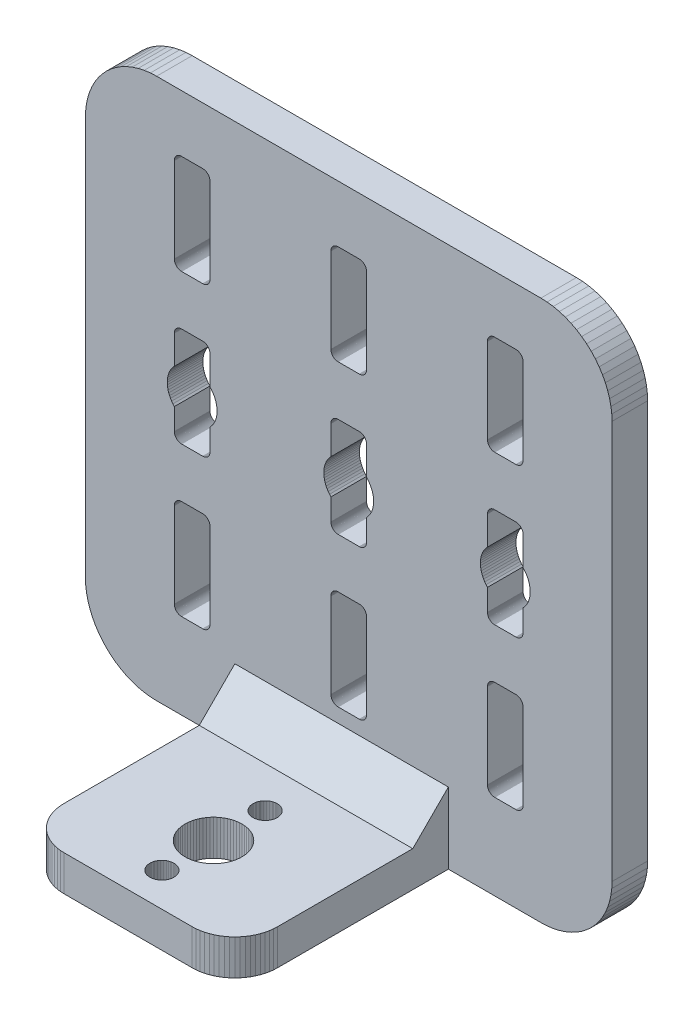
from build123d import *

# Parameters (mm, degrees)
BOSS_EXTRUDE1_DEPTH = 4.999999888
CUT_EXTRUDE1_DEPTH  = 5.999999888
CUT_EXTRUDE2_DEPTH  = 5.999999888
CUT_EXTRUDE3_DEPTH  = 5.999999888
CUT_EXTRUDE4_DEPTH  = 5.999999888
CUT_EXTRUDE5_DEPTH  = 5.999999888
CUT_EXTRUDE6_DEPTH  = 5.999999888
CUT_EXTRUDE7_DEPTH  = 5.999999888
CUT_EXTRUDE8_DEPTH  = 5.999999888
BOSS_EXTRUDE2_DEPTH = 4.999999888
CUT_EXTRUDE9_DEPTH  = 5.999999888
CUT_EXTRUDE10_DEPTH = 5.999999888
CUT_EXTRUDE11_DEPTH = 5.999999888
CUT_EXTRUDE12_DEPTH = 5.999999888
CHAMFER1_SIZE       = 4.999999888


with BuildPart() as part:
    # Sketch1 → Boss-Extrude1 (new body)
    with BuildSketch(Plane(origin=(0, 0, 0), x_dir=(-1, 0, 0), z_dir=(0, 0, -1))):
        Polygon((-0.037951017, 9.128620305), (9.5022e-05, 10.000177294), (9.5022e-05, 66.00017716), (-0.038050115, 66.87156111), (-0.151921064, 67.73648411), (-0.340741128, 68.588189781), (-0.603072345, 69.420203567), (-0.936921744, 70.226185024), (-1.339744776, 71.000002325), (-1.808479428, 71.73576206), (-2.339553088, 72.427876294), (-2.928931266, 73.071070015), (-3.57212103, 73.660440743), (-4.264235497, 74.191518128), (-4.999998957, 74.660256505), (-5.773816258, 75.063079596), (-6.579797715, 75.396925211), (-7.411808241, 75.659260154), (-8.263517171, 75.848080218), (-9.128440171, 75.961947441), (-9.999997914, 75.999997556), (-63.999995589, 75.999997556), (-64.871557057, 75.961947441), (-65.736480057, 75.848080218), (-66.588193178, 75.659260154), (-67.420199513, 75.396925211), (-68.226180971, 75.063079596), (-68.999998271, 74.660256505), (-69.735765457, 74.191518128), (-70.427879691, 73.660440743), (-71.071065962, 73.071070015), (-71.66044414, 72.427876294), (-72.191521525, 71.73576206), (-72.660252452, 71.000002325), (-73.063075542, 70.226185024), (-73.396921158, 69.420203567), (-73.659256101, 68.588189781), (-73.848076165, 67.73648411), (-73.961943388, 66.87156111), (-74.000000954, 65.999999642), (-74.000000954, 9.999999776), (-73.961943388, 9.128442965), (-73.848076165, 8.263518102), (-73.659256101, 7.411809638), (-73.396921158, 6.579798646), (-73.156759143, 6.000000052), (-73.063071255, 5.773818965), (-72.660233496, 5.0000093), (-72.191488623, 4.264253794), (-71.660398119, 3.572152188), (-71.071007749, 2.928971734), (-70.427810306, 2.339607377), (-69.735686005, 1.808544393), (-68.999909934, 1.339824735), (-68.226084998, 0.937015615), (-67.420097212, 0.603182541), (-66.588085905, 0.34086628), (-65.736369205, 0.152063132), (-64.871444046, 0.03821007), (-63.999881857, 0.000173573), (-9.999884182, 0.000173573), (-9.128326439, 0.038226591), (-8.263403439, 0.152096048), (-7.411694509, 0.340915341), (-6.579683983, 0.603247374), (-5.773702526, 0.937095725), (-4.999885225, 1.339919514), (-4.264121764, 1.808653118), (-3.572007298, 2.339729222), (-2.928817534, 2.929105771), (-2.339439356, 3.572297397), (-1.808365696, 4.26440907), (-1.339631044, 5.000173461), (-0.936808012, 5.773990762), (-0.843120628, 6.000173625), (-0.602961325, 6.579973343), (-0.340634, 7.411985562), (-0.151817919, 8.263694909), align=None)
    extrude(amount=-BOSS_EXTRUDE1_DEPTH)

    # Sketch2 → Cut-Extrude1 (cut, through all)
    with BuildSketch(Plane(origin=(0, 0, 0), x_dir=(-1, 0, 0), z_dir=(0, 0, -1))):
        Polygon((-12.999998406, 12.133974582), (-12.92642206, 12.180848047), (-12.857211754, 12.233955786), (-12.792890891, 12.292893603), (-12.733954936, 12.357212603), (-12.680847198, 12.42642384), (-12.633973733, 12.500000186), (-12.593690306, 12.577381916), (-12.560306117, 12.657979503), (-12.534072623, 12.741181068), (-12.515190989, 12.826351449), (-12.503804639, 12.912844308), (-12.499999255, 13.000000268), (-12.499999255, 25.000000373), (-12.503804639, 25.087155402), (-12.515190989, 25.173647329), (-12.534072623, 25.258820504), (-12.560306117, 25.342019275), (-12.593690306, 25.422617793), (-12.633973733, 25.499999523), (-12.680847198, 25.573575869), (-12.733954936, 25.642788038), (-12.792890891, 25.707107037), (-12.857211754, 25.766044855), (-12.92642206, 25.819152594), (-12.999998406, 25.866026059), (-13.077380136, 25.906307623), (-13.157978654, 25.939691812), (-13.241179287, 25.965925306), (-13.3263506, 25.98480694), (-13.412842527, 25.996195152), (-13.499997556, 26.000000536), (-16.499998048, 26.000000536), (-16.58715494, 25.996195152), (-16.673646867, 25.98480694), (-16.758818179, 25.965925306), (-16.842018813, 25.939691812), (-16.922617331, 25.906307623), (-17.000000924, 25.866026059), (-17.073575407, 25.819152594), (-17.142785713, 25.766044855), (-17.207104713, 25.707107037), (-17.266042531, 25.642788038), (-17.319150269, 25.573575869), (-17.366023734, 25.499999523), (-17.406307161, 25.422617793), (-17.43969135, 25.342019275), (-17.465924844, 25.258820504), (-17.484806478, 25.173647329), (-17.496192828, 25.087155402), (-17.499998212, 25.000000373), (-17.499998212, 13.000000268), (-17.496192828, 12.912844308), (-17.484806478, 12.826351449), (-17.465924844, 12.741181068), (-17.43969135, 12.657979503), (-17.406307161, 12.577381916), (-17.366023734, 12.500000186), (-17.319150269, 12.42642384), (-17.266042531, 12.357212603), (-17.207104713, 12.292893603), (-17.142785713, 12.233955786), (-17.073575407, 12.180848047), (-17.000000924, 12.133974582), (-16.922617331, 12.093692087), (-16.842018813, 12.060306966), (-16.758818179, 12.034074403), (-16.673646867, 12.015191838), (-16.58715494, 12.003805488), (-16.499998048, 12.000000104), (-13.499997556, 12.000000104), (-13.412842527, 12.003805488), (-13.3263506, 12.015191838), (-13.241179287, 12.034074403), (-13.157978654, 12.060306966), (-13.077380136, 12.093692087), align=None)
    extrude(amount=-CUT_EXTRUDE1_DEPTH, mode=Mode.SUBTRACT)

    # Sketch3 → Cut-Extrude2 (cut, through all)
    with BuildSketch(Plane(origin=(0, 0, 0), x_dir=(-1, 0, 0), z_dir=(0, 0, -1))):
        Polygon((-39.207104594, 25.707107037), (-39.266042411, 25.642788038), (-39.31915015, 25.573575869), (-39.366025478, 25.499999523), (-39.406307042, 25.422617793), (-39.439689368, 25.342019275), (-39.465922862, 25.258820504), (-39.484806359, 25.173647329), (-39.496194571, 25.087155402), (-39.500001818, 25.000000373), (-39.500001818, 13.000000268), (-39.496194571, 12.912844308), (-39.484806359, 12.826351449), (-39.465922862, 12.741181068), (-39.439689368, 12.657979503), (-39.406307042, 12.577381916), (-39.366025478, 12.500000186), (-39.31915015, 12.42642384), (-39.266042411, 12.357212603), (-39.207104594, 12.292893603), (-39.142787457, 12.233955786), (-39.073575288, 12.180848047), (-38.999997079, 12.133974582), (-38.922615349, 12.093692087), (-38.842018694, 12.060306966), (-38.75881806, 12.034074403), (-38.673646748, 12.015191838), (-38.587152958, 12.003805488), (-38.499999791, 12.000000104), (-35.499997437, 12.000000104), (-35.41284427, 12.003805488), (-35.32635048, 12.015191838), (-35.241179168, 12.034074403), (-35.157978535, 12.060306966), (-35.077381879, 12.093692087), (-35.000000149, 12.133974582), (-34.92642194, 12.180848047), (-34.857209772, 12.233955786), (-34.792892635, 12.292893603), (-34.733954817, 12.357212603), (-34.680847079, 12.42642384), (-34.633971751, 12.500000186), (-34.593690187, 12.577381916), (-34.560304135, 12.657979503), (-34.534074366, 12.741181068), (-34.51519087, 12.826351449), (-34.503802657, 12.912844308), (-34.499999136, 13.000000268), (-34.499999136, 25.000000373), (-34.503802657, 25.087155402), (-34.51519087, 25.173647329), (-34.534074366, 25.258820504), (-34.560304135, 25.342019275), (-34.593690187, 25.422617793), (-34.633971751, 25.499999523), (-34.680847079, 25.573575869), (-34.733954817, 25.642788038), (-34.792892635, 25.707107037), (-34.857209772, 25.766044855), (-34.92642194, 25.819152594), (-35.000000149, 25.866026059), (-35.077381879, 25.906307623), (-35.157978535, 25.939691812), (-35.241179168, 25.965925306), (-35.32635048, 25.98480694), (-35.41284427, 25.996195152), (-35.499997437, 26.000000536), (-38.499999791, 26.000000536), (-38.587152958, 25.996195152), (-38.673646748, 25.98480694), (-38.75881806, 25.965925306), (-38.842018694, 25.939691812), (-38.922615349, 25.906307623), (-38.999997079, 25.866026059), (-39.073575288, 25.819152594), (-39.142787457, 25.766044855), align=None)
    extrude(amount=-CUT_EXTRUDE2_DEPTH, mode=Mode.SUBTRACT)

    # Sketch4 → Cut-Extrude3 (cut, through all)
    with BuildSketch(Plane(origin=(0, 0, 0), x_dir=(-1, 0, 0), z_dir=(0, 0, -1))):
        Polygon((-12.534072623, 33.741179854), (-12.515190989, 33.826351166), (-12.503804639, 33.912844956), (-12.499999255, 34.000001848), (-12.499999255, 37.050511688), (-12.298546731, 37.274654955), (-12.117123231, 37.515301257), (-11.957073584, 37.770662457), (-11.819586158, 38.03884238), (-11.705677956, 38.317859173), (-11.616196483, 38.605637848), (-11.551801115, 38.900051266), (-11.512974277, 39.198908955), (-11.499999091, 39.500001818), (-11.512974277, 39.801090956), (-11.551801115, 40.09995237), (-11.616196483, 40.394362062), (-11.705677956, 40.682140738), (-11.819586158, 40.961157531), (-11.957073584, 41.229337454), (-12.117123231, 41.484698653), (-12.298546731, 41.725344956), (-12.499999255, 41.949488223), (-12.499999255, 46.000000089), (-12.503804639, 46.087156981), (-12.515190989, 46.173647046), (-12.534072623, 46.258818358), (-12.560306117, 46.342018992), (-12.593690306, 46.422619373), (-12.633973733, 46.500001103), (-12.680847198, 46.573575586), (-12.733954936, 46.642787755), (-12.792890891, 46.707108617), (-12.857211754, 46.766046435), (-12.92642206, 46.819150448), (-12.999998406, 46.866025776), (-13.077380136, 46.90630734), (-13.157978654, 46.939693391), (-13.241179287, 46.965926886), (-13.3263506, 46.984806657), (-13.412842527, 46.996198595), (-13.499997556, 46.999998391), (-16.499998048, 46.999998391), (-16.58715494, 46.996198595), (-16.673646867, 46.984806657), (-16.758818179, 46.965926886), (-16.842018813, 46.939693391), (-16.922617331, 46.90630734), (-17.000000924, 46.866025776), (-17.073575407, 46.819150448), (-17.142785713, 46.766046435), (-17.207104713, 46.707108617), (-17.266042531, 46.642787755), (-17.319150269, 46.573575586), (-17.366023734, 46.500001103), (-17.406307161, 46.422619373), (-17.43969135, 46.342018992), (-17.465924844, 46.258818358), (-17.484806478, 46.173647046), (-17.496192828, 46.087156981), (-17.499998212, 46.000000089), (-17.499998212, 41.949488223), (-17.701450735, 41.725344956), (-17.882874236, 41.484698653), (-18.042923883, 41.229337454), (-18.180411309, 40.961157531), (-18.294317648, 40.682140738), (-18.383800983, 40.394362062), (-18.448194489, 40.09995237), (-18.48702319, 39.801090956), (-18.499998376, 39.500001818), (-18.48702319, 39.198908955), (-18.448194489, 38.900051266), (-18.383800983, 38.605637848), (-18.294317648, 38.317859173), (-18.180411309, 38.03884238), (-18.042923883, 37.770662457), (-17.882874236, 37.515301257), (-17.701450735, 37.274654955), (-17.499998212, 37.050511688), (-17.499998212, 34.000001848), (-17.496192828, 33.912844956), (-17.484806478, 33.826351166), (-17.465924844, 33.741179854), (-17.43969135, 33.65797922), (-17.406307161, 33.577382565), (-17.366023734, 33.500000834), (-17.319150269, 33.426422626), (-17.266042531, 33.357214183), (-17.207104713, 33.29289332), (-17.142785713, 33.233955503), (-17.073575407, 33.180847764), (-17.000000924, 33.133976161), (-16.922617331, 33.093687147), (-16.842018813, 33.060308546), (-16.758818179, 33.034075052), (-16.673646867, 33.015191555), (-16.58715494, 33.003807068), (-16.499998048, 32.999999821), (-13.499997556, 32.999999821), (-13.412842527, 33.003807068), (-13.3263506, 33.015191555), (-13.241179287, 33.034075052), (-13.157978654, 33.060308546), (-13.077380136, 33.093687147), (-12.999998406, 33.133976161), (-12.92642206, 33.180847764), (-12.857211754, 33.233955503), (-12.792890891, 33.29289332), (-12.733954936, 33.357214183), (-12.680847198, 33.426422626), (-12.633973733, 33.500000834), (-12.593690306, 33.577382565), (-12.560306117, 33.65797922), align=None)
    extrude(amount=-CUT_EXTRUDE3_DEPTH, mode=Mode.SUBTRACT)

    # Sketch5 → Cut-Extrude4 (cut, through all)
    with BuildSketch(Plane(origin=(0, 0, 0), x_dir=(-1, 0, 0), z_dir=(0, 0, -1))):
        Polygon((-35.41284427, 33.003807068), (-35.32635048, 33.015191555), (-35.241179168, 33.034075052), (-35.157978535, 33.060308546), (-35.077381879, 33.093687147), (-35.000000149, 33.133976161), (-34.92642194, 33.180847764), (-34.857209772, 33.233955503), (-34.792892635, 33.29289332), (-34.733954817, 33.357214183), (-34.680847079, 33.426422626), (-34.633971751, 33.500000834), (-34.593690187, 33.577382565), (-34.560304135, 33.65797922), (-34.534074366, 33.741179854), (-34.51519087, 33.826351166), (-34.503802657, 33.912844956), (-34.499999136, 34.000001848), (-34.499999136, 37.050511688), (-34.298546612, 37.274654955), (-34.117121249, 37.515301257), (-33.957075328, 37.770662457), (-33.819586039, 38.03884238), (-33.705677837, 38.317859173), (-33.616196364, 38.605637848), (-33.551800996, 38.900051266), (-33.512972295, 39.198908955), (-33.499997109, 39.500001818), (-33.513048265, 39.801066238), (-33.551861796, 40.099929622), (-33.616242221, 40.394342583), (-33.705709087, 40.6821258), (-33.819603127, 40.961148374), (-33.957078804, 41.229335275), (-34.000001848, 41.297823191), (-34.117121249, 41.484698653), (-34.298546612, 41.725344956), (-34.499999136, 41.949488223), (-34.499999136, 46.000000089), (-34.503802657, 46.087156981), (-34.51519087, 46.173647046), (-34.534074366, 46.258818358), (-34.560304135, 46.342018992), (-34.593690187, 46.422619373), (-34.633971751, 46.500001103), (-34.680847079, 46.573575586), (-34.733954817, 46.642787755), (-34.792892635, 46.707108617), (-34.857209772, 46.766046435), (-34.92642194, 46.819150448), (-35.000000149, 46.866025776), (-35.077381879, 46.90630734), (-35.157978535, 46.939693391), (-35.241179168, 46.965926886), (-35.32635048, 46.984806657), (-35.41284427, 46.996198595), (-35.499997437, 46.999998391), (-38.499999791, 46.999998391), (-38.587152958, 46.996198595), (-38.673646748, 46.984806657), (-38.75881806, 46.965926886), (-38.842018694, 46.939693391), (-38.922615349, 46.90630734), (-38.999997079, 46.866025776), (-39.073575288, 46.819150448), (-39.142787457, 46.766046435), (-39.207104594, 46.707108617), (-39.266042411, 46.642787755), (-39.31915015, 46.573575586), (-39.366025478, 46.500001103), (-39.406307042, 46.422619373), (-39.439689368, 46.342018992), (-39.465922862, 46.258818358), (-39.484806359, 46.173647046), (-39.496194571, 46.087156981), (-39.500001818, 46.000000089), (-39.500001818, 41.949488223), (-39.701450616, 41.725344956), (-39.882872254, 41.484698653), (-40.042921901, 41.229337454), (-40.18041119, 40.961157531), (-40.294319391, 40.682140738), (-40.383800864, 40.394362062), (-40.448196232, 40.09995237), (-40.487024933, 39.801090956), (-40.500000119, 39.500001818), (-40.487024933, 39.198908955), (-40.448196232, 38.900051266), (-40.383800864, 38.605637848), (-40.294319391, 38.317859173), (-40.18041119, 38.03884238), (-40.042921901, 37.770662457), (-39.882872254, 37.515301257), (-39.701450616, 37.274654955), (-39.500001818, 37.050511688), (-39.500001818, 34.000001848), (-39.496194571, 33.912844956), (-39.484806359, 33.826351166), (-39.465922862, 33.741179854), (-39.439689368, 33.65797922), (-39.406307042, 33.577382565), (-39.366025478, 33.500000834), (-39.31915015, 33.426422626), (-39.266042411, 33.357214183), (-39.207104594, 33.29289332), (-39.142787457, 33.233955503), (-39.073575288, 33.180847764), (-38.999997079, 33.133976161), (-38.922615349, 33.093687147), (-38.842018694, 33.060308546), (-38.75881806, 33.034075052), (-38.673646748, 33.015191555), (-38.587152958, 33.003807068), (-38.499999791, 32.999999821), (-35.499997437, 32.999999821), align=None)
    extrude(amount=-CUT_EXTRUDE4_DEPTH, mode=Mode.SUBTRACT)

    # Sketch6 → Cut-Extrude5 (cut, through all)
    with BuildSketch(Plane(origin=(0, 0, 0), x_dir=(-1, 0, 0), z_dir=(0, 0, -1))):
        Polygon((-56.560307741, 12.657979503), (-56.534074247, 12.741181068), (-56.51519075, 12.826351449), (-56.503802538, 12.912844308), (-56.499999017, 13.000000268), (-56.499999017, 25.000000373), (-56.503802538, 25.087155402), (-56.51519075, 25.173647329), (-56.534074247, 25.258820504), (-56.560307741, 25.342019275), (-56.593690068, 25.422617793), (-56.633971632, 25.499999523), (-56.680846959, 25.573575869), (-56.733954698, 25.642788038), (-56.792892516, 25.707107037), (-56.857213378, 25.766044855), (-56.926421821, 25.819152594), (-56.999996305, 25.866026059), (-57.077378035, 25.906307623), (-57.157978415, 25.939691812), (-57.241179049, 25.965925306), (-57.326350361, 25.98480694), (-57.412840426, 25.996195152), (-57.499997318, 26.000000536), (-60.499995947, 26.000000536), (-60.587152839, 25.996195152), (-60.673646629, 25.98480694), (-60.758817941, 25.965925306), (-60.842018574, 25.939691812), (-60.92261523, 25.906307623), (-60.99999696, 25.866026059), (-61.073575169, 25.819152594), (-61.142787337, 25.766044855), (-61.207104474, 25.707107037), (-61.266042292, 25.642788038), (-61.319150031, 25.573575869), (-61.366021633, 25.499999523), (-61.406306922, 25.422617793), (-61.439692974, 25.342019275), (-61.465926468, 25.258820504), (-61.48480624, 25.173647329), (-61.496190727, 25.087155402), (-61.499997973, 25.000000373), (-61.499997973, 13.000000268), (-61.496190727, 12.912844308), (-61.48480624, 12.826351449), (-61.465926468, 12.741181068), (-61.439692974, 12.657979503), (-61.406306922, 12.577381916), (-61.366021633, 12.500000186), (-61.319150031, 12.42642384), (-61.266042292, 12.357212603), (-61.207104474, 12.292893603), (-61.142787337, 12.233955786), (-61.073575169, 12.180848047), (-60.99999696, 12.133974582), (-60.92261523, 12.093692087), (-60.842018574, 12.060306966), (-60.758817941, 12.034074403), (-60.673646629, 12.015191838), (-60.587152839, 12.003805488), (-60.499995947, 12.000000104), (-57.499997318, 12.000000104), (-57.412840426, 12.003805488), (-57.326350361, 12.015191838), (-57.241179049, 12.034074403), (-57.157978415, 12.060306966), (-57.077378035, 12.093692087), (-56.999996305, 12.133974582), (-56.926421821, 12.180848047), (-56.857213378, 12.233955786), (-56.792892516, 12.292893603), (-56.733954698, 12.357212603), (-56.680846959, 12.42642384), (-56.633971632, 12.500000186), (-56.593690068, 12.577381916), align=None)
    extrude(amount=-CUT_EXTRUDE5_DEPTH, mode=Mode.SUBTRACT)

    # Sketch7 → Cut-Extrude6 (cut, through all)
    with BuildSketch(Plane(origin=(0, 0, 0), x_dir=(-1, 0, 0), z_dir=(0, 0, -1))):
        Polygon((-55.957071483, 37.770662457), (-55.819585919, 38.03884238), (-55.705681443, 38.317859173), (-55.616196245, 38.605637848), (-55.551804602, 38.900051266), (-55.512972176, 39.198908955), (-55.500000715, 39.500001818), (-55.512972176, 39.801090956), (-55.551804602, 40.09995237), (-55.616196245, 40.394362062), (-55.705681443, 40.682140738), (-55.819585919, 40.961157531), (-55.957071483, 41.229337454), (-56.117124856, 41.484698653), (-56.298546493, 41.725344956), (-56.499999017, 41.949488223), (-56.499999017, 46.000000089), (-56.503802538, 46.087156981), (-56.51519075, 46.173647046), (-56.534074247, 46.258818358), (-56.560307741, 46.342018992), (-56.593690068, 46.422619373), (-56.633971632, 46.500001103), (-56.680846959, 46.573575586), (-56.733954698, 46.642787755), (-56.792892516, 46.707108617), (-56.857213378, 46.766046435), (-56.926421821, 46.819150448), (-56.999996305, 46.866025776), (-57.077378035, 46.90630734), (-57.157978415, 46.939693391), (-57.241179049, 46.965926886), (-57.326350361, 46.984806657), (-57.412840426, 46.996198595), (-57.499997318, 46.999998391), (-60.499995947, 46.999998391), (-60.587152839, 46.996198595), (-60.673646629, 46.984806657), (-60.758817941, 46.965926886), (-60.842018574, 46.939693391), (-60.92261523, 46.90630734), (-60.99999696, 46.866025776), (-61.073575169, 46.819150448), (-61.142787337, 46.766046435), (-61.207104474, 46.707108617), (-61.266042292, 46.642787755), (-61.319150031, 46.573575586), (-61.366021633, 46.500001103), (-61.406306922, 46.422619373), (-61.439692974, 46.342018992), (-61.465926468, 46.258818358), (-61.48480624, 46.173647046), (-61.496190727, 46.087156981), (-61.499997973, 46.000000089), (-61.499997973, 41.949488223), (-61.701450497, 41.725344956), (-61.88287586, 41.484698653), (-62.042921782, 41.229337454), (-62.180411071, 40.961157531), (-62.294319272, 40.682140738), (-62.383800745, 40.394362062), (-62.448196113, 40.09995237), (-62.487021089, 39.801090956), (-62.5, 39.500001818), (-62.487021089, 39.198908955), (-62.448196113, 38.900051266), (-62.383800745, 38.605637848), (-62.294319272, 38.317859173), (-62.180411071, 38.03884238), (-62.042921782, 37.770662457), (-61.88287586, 37.515301257), (-61.701450497, 37.274654955), (-61.499997973, 37.050511688), (-61.499997973, 34.000001848), (-61.496190727, 33.912844956), (-61.48480624, 33.826351166), (-61.465926468, 33.741179854), (-61.439692974, 33.65797922), (-61.406306922, 33.577382565), (-61.366021633, 33.500000834), (-61.319150031, 33.426422626), (-61.266042292, 33.357214183), (-61.207104474, 33.29289332), (-61.142787337, 33.233955503), (-61.073575169, 33.180847764), (-60.99999696, 33.133976161), (-60.92261523, 33.093687147), (-60.842018574, 33.060308546), (-60.758817941, 33.034075052), (-60.673646629, 33.015191555), (-60.587152839, 33.003807068), (-60.499995947, 32.999999821), (-57.499997318, 32.999999821), (-57.412840426, 33.003807068), (-57.326350361, 33.015191555), (-57.241179049, 33.034075052), (-57.157978415, 33.060308546), (-57.077378035, 33.093687147), (-56.999996305, 33.133976161), (-56.926421821, 33.180847764), (-56.857213378, 33.233955503), (-56.792892516, 33.29289332), (-56.733954698, 33.357214183), (-56.680846959, 33.426422626), (-56.633971632, 33.500000834), (-56.593690068, 33.577382565), (-56.560307741, 33.65797922), (-56.534074247, 33.741179854), (-56.51519075, 33.826351166), (-56.503802538, 33.912844956), (-56.499999017, 34.000001848), (-56.499999017, 37.050511688), (-56.298546493, 37.274654955), (-56.117124856, 37.515301257), align=None)
    extrude(amount=-CUT_EXTRUDE6_DEPTH, mode=Mode.SUBTRACT)

    # Sketch8 → Cut-Extrude7 (cut, through all)
    with BuildSketch(Plane(origin=(0, 0, 0), x_dir=(-1, 0, 0), z_dir=(0, 0, -1))):
        Polygon((-12.92642206, 54.180849344), (-12.857211754, 54.233957082), (-12.792890891, 54.2928949), (-12.733954936, 54.357212037), (-12.680847198, 54.426424205), (-12.633973733, 54.499998689), (-12.593690306, 54.577380419), (-12.560306117, 54.6579808), (-12.534072623, 54.741181433), (-12.515190989, 54.826352745), (-12.503804639, 54.91284281), (-12.499999255, 54.999999702), (-12.499999255, 67.000001669), (-12.503804639, 67.087158561), (-12.515190989, 67.1736449), (-12.534072623, 67.258819938), (-12.560306117, 67.342020571), (-12.593690306, 67.422620952), (-12.633973733, 67.500002682), (-12.680847198, 67.573577166), (-12.733954936, 67.642785609), (-12.792890891, 67.707106471), (-12.857211754, 67.766048014), (-12.92642206, 67.819155753), (-12.999998406, 67.866027355), (-13.077380136, 67.906305194), (-13.157978654, 67.939691246), (-13.241179287, 67.96592474), (-13.3263506, 67.984804511), (-13.412842527, 67.996196449), (-13.499997556, 68.000003695), (-16.499998048, 68.000003695), (-16.58715494, 67.996196449), (-16.673646867, 67.984804511), (-16.758818179, 67.96592474), (-16.842018813, 67.939691246), (-16.922617331, 67.906305194), (-17.000000924, 67.866027355), (-17.073575407, 67.819155753), (-17.142785713, 67.766048014), (-17.207104713, 67.707106471), (-17.266042531, 67.642785609), (-17.319150269, 67.573577166), (-17.366023734, 67.500002682), (-17.406307161, 67.422620952), (-17.43969135, 67.342020571), (-17.465924844, 67.258819938), (-17.484806478, 67.1736449), (-17.496192828, 67.087158561), (-17.499998212, 67.000001669), (-17.499998212, 54.999999702), (-17.496192828, 54.91284281), (-17.484806478, 54.826352745), (-17.465924844, 54.741181433), (-17.43969135, 54.6579808), (-17.406307161, 54.577380419), (-17.366023734, 54.499998689), (-17.319150269, 54.426424205), (-17.266042531, 54.357212037), (-17.207104713, 54.2928949), (-17.142785713, 54.233957082), (-17.073575407, 54.180849344), (-17.000000924, 54.133974016), (-16.922617331, 54.093692452), (-16.842018813, 54.0603064), (-16.758818179, 54.034072906), (-16.673646867, 54.015193135), (-16.58715494, 54.003804922), (-16.499998048, 54.000001401), (-13.499997556, 54.000001401), (-13.412842527, 54.003804922), (-13.3263506, 54.015193135), (-13.241179287, 54.034072906), (-13.157978654, 54.0603064), (-13.077380136, 54.093692452), (-12.999998406, 54.133974016), align=None)
    extrude(amount=-CUT_EXTRUDE7_DEPTH, mode=Mode.SUBTRACT)

    # Sketch9 → Cut-Extrude8 (cut, through all)
    with BuildSketch(Plane(origin=(0, 0, 0), x_dir=(-1, 0, 0), z_dir=(0, 0, -1))):
        Polygon((-34.503802657, 67.087158561), (-34.51519087, 67.1736449), (-34.534074366, 67.258819938), (-34.560304135, 67.342020571), (-34.593690187, 67.422620952), (-34.633971751, 67.500002682), (-34.680847079, 67.573577166), (-34.733954817, 67.642785609), (-34.792892635, 67.707106471), (-34.857209772, 67.766048014), (-34.92642194, 67.819155753), (-35.000000149, 67.866027355), (-35.077381879, 67.906305194), (-35.157978535, 67.939691246), (-35.241179168, 67.96592474), (-35.32635048, 67.984804511), (-35.41284427, 67.996196449), (-35.499997437, 68.000003695), (-38.499999791, 68.000003695), (-38.587152958, 67.996196449), (-38.673646748, 67.984804511), (-38.75881806, 67.96592474), (-38.842018694, 67.939691246), (-38.922615349, 67.906305194), (-38.999997079, 67.866027355), (-39.073575288, 67.819155753), (-39.142787457, 67.766048014), (-39.207104594, 67.707106471), (-39.266042411, 67.642785609), (-39.31915015, 67.573577166), (-39.366025478, 67.500002682), (-39.406307042, 67.422620952), (-39.439689368, 67.342020571), (-39.465922862, 67.258819938), (-39.484806359, 67.1736449), (-39.496194571, 67.087158561), (-39.500001818, 67.000001669), (-39.500001818, 54.999999702), (-39.496194571, 54.91284281), (-39.484806359, 54.826352745), (-39.465922862, 54.741181433), (-39.439689368, 54.6579808), (-39.406307042, 54.577380419), (-39.366025478, 54.499998689), (-39.31915015, 54.426424205), (-39.266042411, 54.357212037), (-39.207104594, 54.2928949), (-39.142787457, 54.233957082), (-39.073575288, 54.180849344), (-38.999997079, 54.133974016), (-38.922615349, 54.093692452), (-38.842018694, 54.0603064), (-38.75881806, 54.034072906), (-38.673646748, 54.015193135), (-38.587152958, 54.003804922), (-38.499999791, 54.000001401), (-35.499997437, 54.000001401), (-35.41284427, 54.003804922), (-35.32635048, 54.015193135), (-35.241179168, 54.034072906), (-35.157978535, 54.0603064), (-35.077381879, 54.093692452), (-35.000000149, 54.133974016), (-34.92642194, 54.180849344), (-34.857209772, 54.233957082), (-34.792892635, 54.2928949), (-34.733954817, 54.357212037), (-34.680847079, 54.426424205), (-34.633971751, 54.499998689), (-34.593690187, 54.577380419), (-34.560304135, 54.6579808), (-34.534074366, 54.741181433), (-34.51519087, 54.826352745), (-34.503802657, 54.91284281), (-34.499999136, 54.999999702), (-34.499999136, 67.000001669), align=None)
    extrude(amount=-CUT_EXTRUDE8_DEPTH, mode=Mode.SUBTRACT)

    # Sketch10 → Boss-Extrude2 (add)
    with BuildSketch(Plane.XZ):
        Polygon((44.999994338, 35.000000149), (26.999998838, 35.000000149), (26.477064937, 34.977167845), (25.958109647, 34.908846021), (25.4470855, 34.795552492), (24.947877973, 34.638155252), (24.464288726, 34.437846392), (23.999998346, 34.196153283), (23.55854027, 33.914912492), (23.143272847, 33.596266061), (22.757358849, 33.242639154), (22.403731942, 32.856725156), (22.085085511, 32.441459596), (21.80384472, 31.999997795), (21.562151611, 31.535707414), (21.361842752, 31.05212003), (21.204443648, 30.552912503), (21.091151983, 30.041888356), (21.022830158, 29.522933066), (20.999997854, 28.999999166), (20.999997854, 4.999999888), (50.999999046, 4.999999888), (50.999999046, 28.999999166), (50.977166742, 29.522933066), (50.908844918, 30.041888356), (50.795555115, 30.552912503), (50.638154149, 31.05212003), (50.43784529, 31.535707414), (50.19615218, 31.999997795), (49.914911389, 32.441459596), (49.596264958, 32.856725156), (49.242638052, 33.242639154), (48.856724054, 33.596266061), (48.441454768, 33.914912492), (48.000000417, 34.196153283), (47.535710037, 34.437846392), (47.052118927, 34.638155252), (46.552911401, 34.795552492), (46.041883528, 34.908846021), (45.522931963, 34.977167845), align=None)
    extrude(amount=-BOSS_EXTRUDE2_DEPTH)

    # Sketch11 → Cut-Extrude9 (cut, through all)
    with BuildSketch(Plane(origin=(0, 4.999999888, 0), x_dir=(-1, 0, 0), z_dir=(0, 1, 0))):
        Polygon((-36.295201629, 17.424173653), (-36.439992487, 17.392072827), (-36.581434309, 17.347477376), (-36.718450487, 17.290722579), (-36.849997938, 17.22224243), (-36.975078285, 17.14255847), (-37.092737854, 17.052274197), (-37.202078849, 16.952080652), (-37.302274257, 16.842737794), (-37.392556667, 16.725080088), (-37.472240627, 16.599999741), (-37.540722638, 16.468450427), (-37.597477436, 16.33143425), (-37.642072886, 16.189992428), (-37.674169987, 16.04520157), (-37.693530321, 15.898164362), (-37.699997425, 15.749998391), (-37.693530321, 15.601834282), (-37.674169987, 15.454797074), (-37.642072886, 15.310007147), (-37.597477436, 15.168565325), (-37.540722638, 15.031548217), (-37.472240627, 14.899998903), (-37.392556667, 14.774919488), (-37.302274257, 14.65726085), (-37.202078849, 14.547917992), (-37.092737854, 14.447724447), (-36.975078285, 14.357441105), (-36.849997938, 14.277755283), (-36.718450487, 14.209276065), (-36.581434309, 14.152522199), (-36.439992487, 14.107925817), (-36.295201629, 14.075826854), (-36.148164421, 14.056468382), (-35.99999845, 14.049999416), (-35.851832479, 14.056468382), (-35.704795271, 14.075826854), (-35.560004413, 14.107925817), (-35.418562591, 14.152522199), (-35.281546414, 14.209276065), (-35.149998963, 14.277755283), (-35.024918616, 14.357441105), (-34.907259047, 14.447724447), (-34.797918051, 14.547917992), (-34.697722644, 14.65726085), (-34.607440233, 14.774919488), (-34.527756274, 14.899998903), (-34.459274262, 15.031548217), (-34.402519464, 15.168565325), (-34.357924014, 15.310007147), (-34.325826913, 15.454797074), (-34.306466579, 15.601834282), (-34.299999475, 15.749998391), (-34.306466579, 15.898164362), (-34.325826913, 16.04520157), (-34.357924014, 16.189992428), (-34.402519464, 16.33143425), (-34.459274262, 16.468450427), (-34.527756274, 16.599999741), (-34.607440233, 16.725080088), (-34.697722644, 16.842737794), (-34.797918051, 16.952080652), (-34.907259047, 17.052274197), (-35.024918616, 17.14255847), (-35.149998963, 17.22224243), (-35.281546414, 17.290722579), (-35.418562591, 17.347477376), (-35.560004413, 17.392072827), (-35.704795271, 17.424173653), (-35.851832479, 17.443530262), (-35.99999845, 17.449999228), (-36.148164421, 17.443530262), align=None)
    extrude(amount=-CUT_EXTRUDE9_DEPTH, mode=Mode.SUBTRACT)

    # Sketch12 → Cut-Extrude10 (cut, through all)
    with BuildSketch(Plane(origin=(0, 4.999999888, 0), x_dir=(-1, 0, 0), z_dir=(0, 1, 0))):
        Polygon((-36.348622292, 26.984777302), (-36.694590002, 26.93923004), (-37.035275251, 26.863703504), (-37.368077785, 26.758769527), (-37.690471858, 26.625230908), (-37.999998778, 26.464100927), (-38.294304162, 26.276607066), (-38.571149111, 26.064177975), (-38.828425109, 25.828426704), (-39.064176381, 25.571148843), (-39.276607335, 25.294305757), (-39.464101195, 24.99999851), (-39.625231177, 24.69047159), (-39.758767933, 24.368081242), (-39.86370191, 24.035274982), (-39.939228445, 23.694591597), (-39.98477757, 23.348622024), (-39.999999106, 23.000000045), (-39.98477757, 22.651376203), (-39.939228445, 22.30540663), (-39.86370191, 21.964723244), (-39.758767933, 21.631918848), (-39.625231177, 21.309526637), (-39.464101195, 20.999999717), (-39.276607335, 20.705694333), (-39.064176381, 20.428849384), (-38.828425109, 20.171571523), (-38.571149111, 19.935822114), (-38.294304162, 19.72339116), (-37.999998778, 19.5358973), (-37.690471858, 19.374769181), (-37.368077785, 19.2412287), (-37.035275251, 19.136296585), (-36.694590002, 19.060768187), (-36.348622292, 19.015220925), (-35.99999845, 18.999999389), (-35.651374608, 19.015220925), (-35.305406898, 19.060768187), (-34.96472165, 19.136296585), (-34.631919116, 19.2412287), (-34.309525043, 19.374769181), (-34.000001848, 19.5358973), (-33.705692738, 19.72339116), (-33.42884779, 19.935822114), (-33.171571791, 20.171571523), (-32.93582052, 20.428849384), (-32.723389566, 20.705694333), (-32.535895705, 20.999999717), (-32.374765724, 21.309526637), (-32.241228968, 21.631918848), (-32.136294991, 21.964723244), (-32.060768455, 22.30540663), (-32.015219331, 22.651376203), (-31.999997795, 23.000000045), (-32.015219331, 23.348622024), (-32.060768455, 23.694591597), (-32.136294991, 24.035274982), (-32.241228968, 24.368081242), (-32.374765724, 24.69047159), (-32.535895705, 24.99999851), (-32.723389566, 25.294305757), (-32.93582052, 25.571148843), (-33.171571791, 25.828426704), (-33.42884779, 26.064177975), (-33.705692738, 26.276607066), (-34.000001848, 26.464100927), (-34.309525043, 26.625230908), (-34.631919116, 26.758769527), (-34.96472165, 26.863703504), (-35.305406898, 26.93923004), (-35.651374608, 26.984777302), (-35.99999845, 26.999998838), align=None)
    extrude(amount=-CUT_EXTRUDE10_DEPTH, mode=Mode.SUBTRACT)

    # Sketch13 → Cut-Extrude11 (cut, through all)
    with BuildSketch(Plane(origin=(0, 4.999999888, 0), x_dir=(-1, 0, 0), z_dir=(0, 1, 0))):
        Polygon((-36.849997938, 31.722243875), (-36.975078285, 31.64255619), (-37.092737854, 31.55227378), (-37.202078849, 31.452082098), (-37.302274257, 31.342737377), (-37.392556667, 31.225079671), (-37.472240627, 31.099999323), (-37.540722638, 30.96845001), (-37.597477436, 30.831433833), (-37.642072886, 30.689992011), (-37.674169987, 30.545201153), (-37.693530321, 30.398163944), (-37.699997425, 30.249999836), (-37.693530321, 30.101835728), (-37.674169987, 29.95479852), (-37.642072886, 29.810007662), (-37.597477436, 29.66856584), (-37.540722638, 29.531549662), (-37.472240627, 29.399998486), (-37.392556667, 29.274920002), (-37.302274257, 29.157260433), (-37.202078849, 29.047917575), (-37.092737854, 28.947724029), (-36.975078285, 28.857439756), (-36.849997938, 28.777755797), (-36.718450487, 28.709277511), (-36.581434309, 28.652522713), (-36.439992487, 28.6079254), (-36.295201629, 28.575826436), (-36.148164421, 28.556469828), (-35.99999845, 28.549998999), (-35.851832479, 28.556469828), (-35.704795271, 28.575826436), (-35.560004413, 28.6079254), (-35.418562591, 28.652522713), (-35.281546414, 28.709277511), (-35.149998963, 28.777755797), (-35.024918616, 28.857439756), (-34.907259047, 28.947724029), (-34.797918051, 29.047917575), (-34.697722644, 29.157260433), (-34.607440233, 29.274920002), (-34.527756274, 29.399998486), (-34.459274262, 29.531549662), (-34.402519464, 29.66856584), (-34.357924014, 29.810007662), (-34.325826913, 29.95479852), (-34.306466579, 30.101835728), (-34.299999475, 30.249999836), (-34.306466579, 30.398163944), (-34.325826913, 30.545201153), (-34.357924014, 30.689992011), (-34.402519464, 30.831433833), (-34.459274262, 30.96845001), (-34.527756274, 31.099999323), (-34.607440233, 31.225079671), (-34.697722644, 31.342737377), (-34.797918051, 31.452082098), (-34.907259047, 31.55227378), (-35.024918616, 31.64255619), (-35.149998963, 31.722243875), (-35.281546414, 31.790722162), (-35.418562591, 31.847476959), (-35.560004413, 31.892072409), (-35.704795271, 31.924173236), (-35.851832479, 31.943529844), (-35.99999845, 31.950000674), (-36.148164421, 31.943529844), (-36.295201629, 31.924173236), (-36.439992487, 31.892072409), (-36.581434309, 31.847476959), (-36.718450487, 31.790722162), align=None)
    extrude(amount=-CUT_EXTRUDE11_DEPTH, mode=Mode.SUBTRACT)

    # Sketch14 → Cut-Extrude12 (cut, through all)
    with BuildSketch(Plane.XY.offset(4.999999888)):
        Polygon((60.587152839, 54.003804922), (60.673646629, 54.015193135), (60.758817941, 54.034072906), (60.842018574, 54.0603064), (60.92261523, 54.093692452), (60.99999696, 54.133974016), (61.073575169, 54.180849344), (61.142787337, 54.233957082), (61.207104474, 54.2928949), (61.266042292, 54.357212037), (61.319150031, 54.426424205), (61.366021633, 54.499998689), (61.406306922, 54.577380419), (61.439692974, 54.6579808), (61.465926468, 54.741181433), (61.48480624, 54.826352745), (61.496190727, 54.91284281), (61.499997973, 54.999999702), (61.499997973, 67.000001669), (61.496190727, 67.087158561), (61.48480624, 67.1736449), (61.465926468, 67.258819938), (61.439692974, 67.342020571), (61.406306922, 67.422620952), (61.366021633, 67.500002682), (61.319150031, 67.573577166), (61.266042292, 67.642785609), (61.207104474, 67.707106471), (61.142787337, 67.766048014), (61.073575169, 67.819155753), (60.99999696, 67.866027355), (60.92261523, 67.906305194), (60.842018574, 67.939691246), (60.758817941, 67.96592474), (60.673646629, 67.984804511), (60.587152839, 67.996196449), (60.499995947, 68.000003695), (57.499997318, 68.000003695), (57.412840426, 67.996196449), (57.326350361, 67.984804511), (57.241179049, 67.96592474), (57.157978415, 67.939691246), (57.077378035, 67.906305194), (56.999996305, 67.866027355), (56.926421821, 67.819155753), (56.857213378, 67.766048014), (56.792892516, 67.707106471), (56.733954698, 67.642785609), (56.680846959, 67.573577166), (56.633971632, 67.500002682), (56.593690068, 67.422620952), (56.560307741, 67.342020571), (56.534074247, 67.258819938), (56.51519075, 67.1736449), (56.503802538, 67.087158561), (56.499999017, 67.000001669), (56.499999017, 54.999999702), (56.503802538, 54.91284281), (56.51519075, 54.826352745), (56.534074247, 54.741181433), (56.560307741, 54.6579808), (56.593690068, 54.577380419), (56.633971632, 54.499998689), (56.680846959, 54.426424205), (56.733954698, 54.357212037), (56.792892516, 54.2928949), (56.857213378, 54.233957082), (56.926421821, 54.180849344), (56.999996305, 54.133974016), (57.077378035, 54.093692452), (57.157978415, 54.0603064), (57.241179049, 54.034072906), (57.326350361, 54.015193135), (57.412840426, 54.003804922), (57.499997318, 54.000001401), (60.499995947, 54.000001401), align=None)
    extrude(amount=-CUT_EXTRUDE12_DEPTH, mode=Mode.SUBTRACT)

    # Chamfer1
    chamfer1_edges = [part.edges().sort_by_distance(p)[0] for p in [
        (35.99999845, 4.999999888, 4.999999888),
    ]]
    chamfer(chamfer1_edges, length=CHAMFER1_SIZE)


solid = part.part
